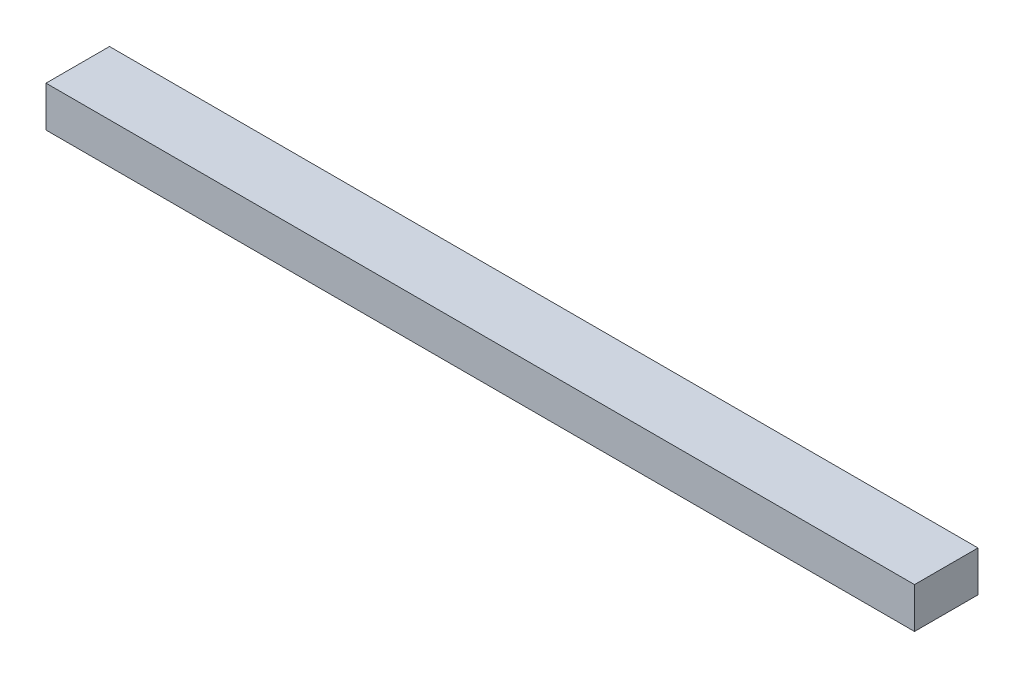
from build123d import *

# Parameters (mm, degrees)
ESQUISSE1_W        = 342
ESQUISSE1_H        = 16
BOSS_EXTRU_1_DEPTH = 25


with BuildPart() as part:
    # Esquisse1 → Boss.-Extru.1 (new body)
    with BuildSketch(Plane.XY):
        with Locations((30, -185)):
            Rectangle(ESQUISSE1_W, ESQUISSE1_H)
    extrude(amount=BOSS_EXTRU_1_DEPTH)


solid = part.part
